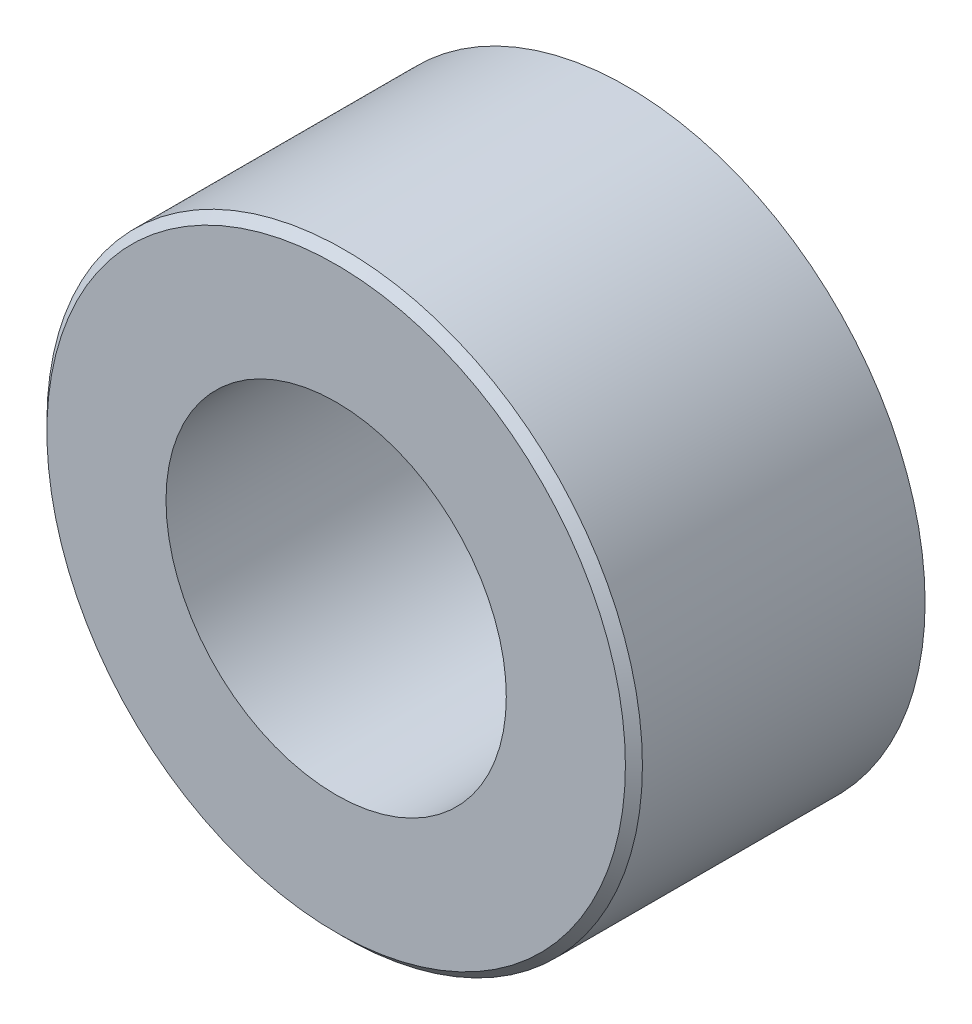
from build123d import *

# Parameters (mm, degrees)
SKETCH1_R           = 7
SKETCH1_R_2         = 4
BOSS_EXTRUDE1_DEPTH = 8
CHAMFER1_SIZE       = 0.2
CHAMFER2_SIZE       = 2
CHAMFER2_SIZE2      = 1.154700538


with BuildPart() as part:
    # Sketch1 → Boss-Extrude1 (new body)
    with BuildSketch(Plane.XY):
        Circle(SKETCH1_R)
        Circle(SKETCH1_R_2, mode=Mode.SUBTRACT)
    extrude(amount=BOSS_EXTRUDE1_DEPTH)

    # Chamfer1
    chamfer1_edges = [part.edges().sort_by_distance(p)[0] for p in [
        (-7, 0, 8),
    ]]
    chamfer(chamfer1_edges, length=CHAMFER1_SIZE)

    # Chamfer2
    chamfer2_edges = [part.edges().sort_by_distance(p)[0] for p in [
        (-7, 0, 0),
    ]]
    chamfer2_side = [part.faces().sort_by_distance(p)[0] for p in [
        (-6.802010101, 0, 0),
    ]]
    chamfer(chamfer2_edges, length=CHAMFER2_SIZE, length2=CHAMFER2_SIZE2, reference=chamfer2_side[0])


solid = part.part
